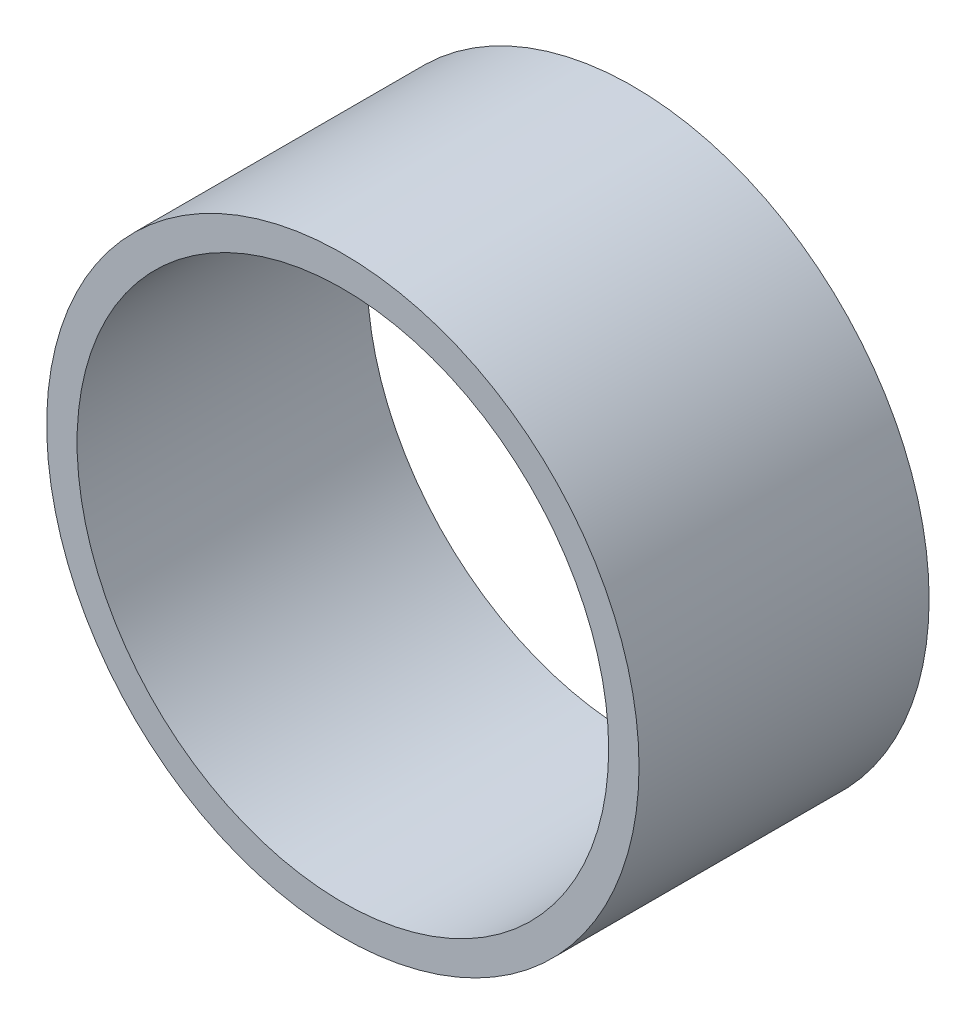
from build123d import *

# Parameters (mm, degrees)
SKETCH1_R           = 2.552350598
SKETCH1_R_2         = 2.290708709
BOSS_EXTRUDE1_DEPTH = 2.5


with BuildPart() as part:
    # Sketch1 → Boss-Extrude1 (new body)
    with BuildSketch(Plane.XY):
        Circle(SKETCH1_R)
        Circle(SKETCH1_R_2, mode=Mode.SUBTRACT)
    extrude(amount=BOSS_EXTRUDE1_DEPTH)


solid = part.part
